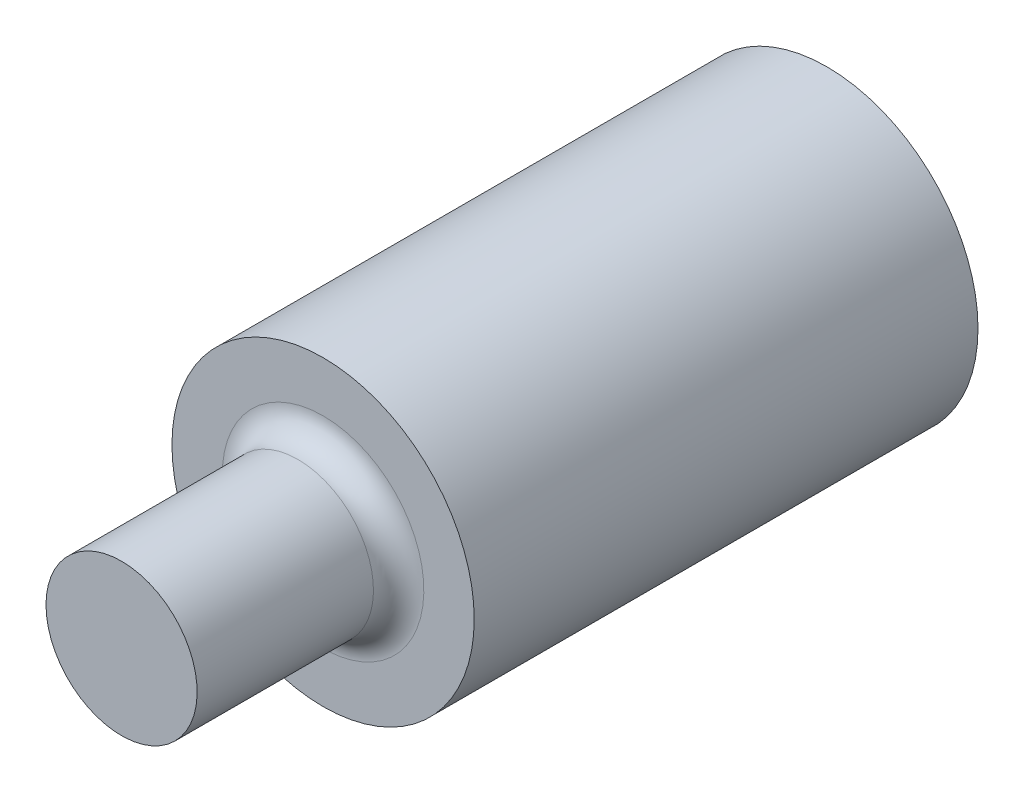
from build123d import *

# Parameters (mm, degrees)
SKETCH3_W               = 75
SKETCH3_H               = 3.512766304
CUT_EXTRUDE1_DEPTH      = 2.5
CUT_EXTRUDE1_DEPTH_BACK = 2.5


with BuildPart() as part:
    # Sketch2 → Revolve1 (revolve)
    with BuildSketch(Plane(origin=(0, 0, 0), x_dir=(0, 0, -1), z_dir=(1, 0, 0))):
        with BuildLine():
            Line((-29, 0.75), (28.75, 0.75))
            ThreePointArc((28.75, 0.75), (28.926776695, 0.823223305), (29, 1))
            Line((29, 1), (29, 1.5))
            Line((29, 1.5), (34, 1.5))
            Line((34, 1.5), (34, 0))
            Line((34, 0), (-29, 0))
            Line((-29, 0), (-29, 0.75))
        make_face()
    revolve(axis=Axis((0, 0, -34), (0, 0, 1)))

    # Sketch3 → Cut-Extrude1 (cut, two sides)
    with BuildSketch(Plane(origin=(0, 0, 0), x_dir=(0, 0, -1), z_dir=(1, 0, 0))) as cut_extrude1_sk:
        with Locations((-10.5, -0.065051228)):
            Rectangle(SKETCH3_W, SKETCH3_H)
    extrude(amount=CUT_EXTRUDE1_DEPTH, mode=Mode.SUBTRACT)
    extrude(cut_extrude1_sk.sketch, amount=-CUT_EXTRUDE1_DEPTH_BACK, mode=Mode.SUBTRACT)


solid = part.part
